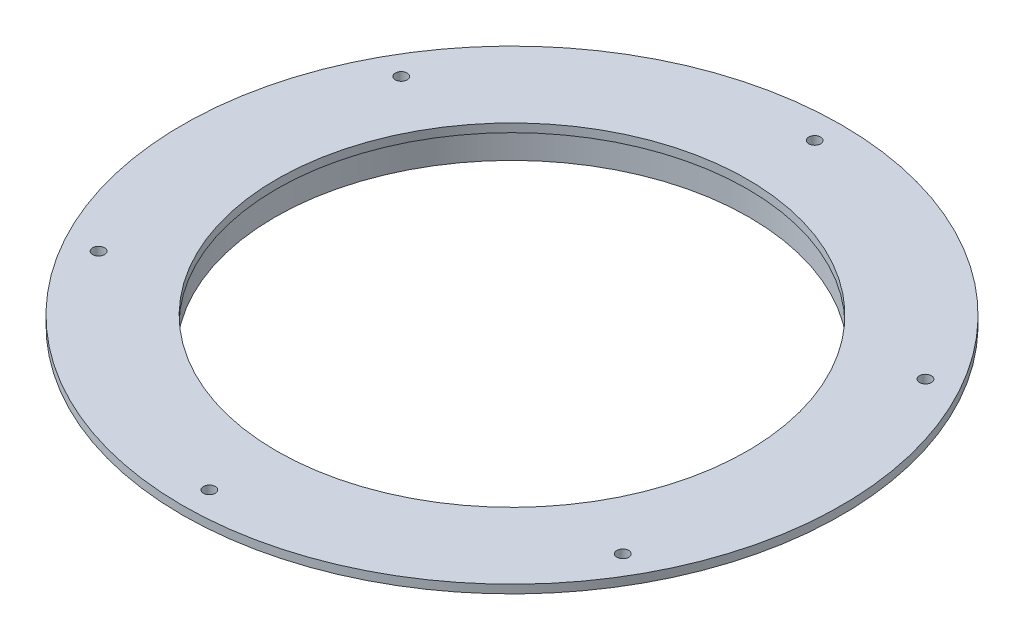
from build123d import *

# Parameters (mm, degrees)
F_8_CLEARANCE_HOLE1_D     = 4.4958
F_8_CLEARANCE_HOLE1_DEPTH = 3.176
CIRPATTERN1_COUNT         = 6
SKETCH4_R                 = 88.9
CUT_EXTRUDE1_DEPTH        = 13.7


with BuildPart() as part:
    # Sketch1 → Revolve1 (revolve)
    with BuildSketch(Plane(origin=(0, 0, 0), x_dir=(0, 0, -1), z_dir=(1, 0, 0))):
        Polygon((89.535, 0), (92.71, 0), (92.71, 9.525), (124.46, 9.525), (124.46, 12.7), (0, 12.7), (0, 9.525), (89.535, 9.525), align=None)
    revolve(axis=Axis((0, 0, 0), (0, 1, 0)))

    # #8 Clearance Hole1
    with Locations(Plane(origin=(0, 12.7, 0), x_dir=(1, 0, 0), z_dir=(0, 1, 0))):
        with Locations((0, 114.3)):
            f_8_clearance_hole1 = Hole(F_8_CLEARANCE_HOLE1_D / 2, depth=F_8_CLEARANCE_HOLE1_DEPTH)

    # CirPattern1: #8 Clearance Hole1 ×6 about axis
    cirpattern1_axis = Axis((0, 0, 0), (0, 1, 0))
    for i in range(1, CIRPATTERN1_COUNT):
        add(f_8_clearance_hole1.rotate(cirpattern1_axis, i * 360 / CIRPATTERN1_COUNT), mode=Mode.SUBTRACT)

    # Sketch4 → Cut-Extrude1 (cut, through all)
    with BuildSketch(Plane(origin=(0, 12.7, 0), x_dir=(1, 0, 0), z_dir=(0, 1, 0))):
        Circle(SKETCH4_R)
    extrude(amount=-CUT_EXTRUDE1_DEPTH, mode=Mode.SUBTRACT)


solid = part.part
